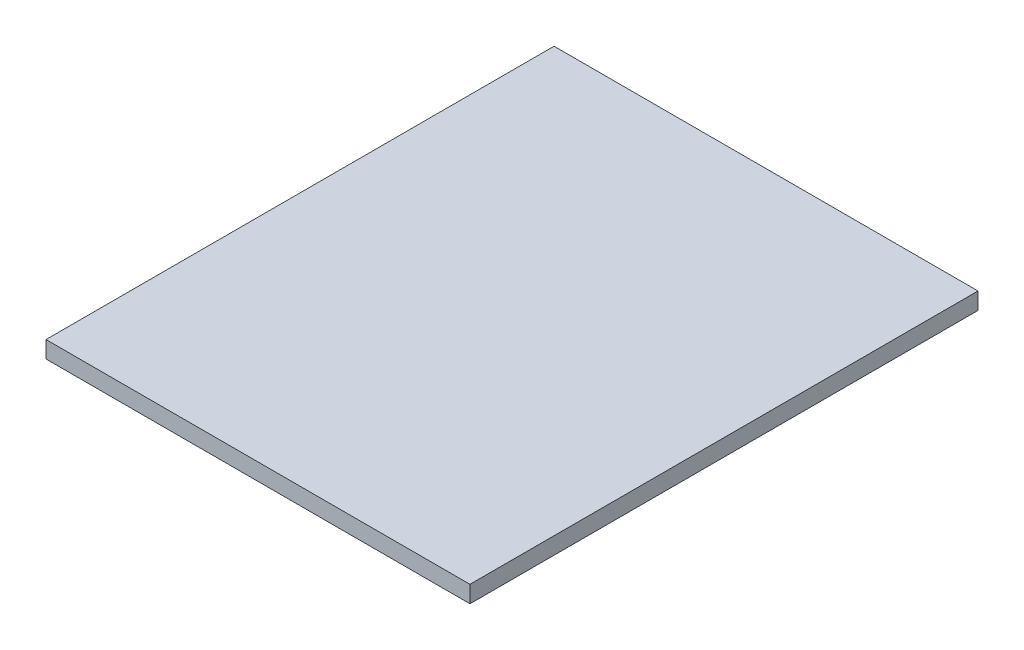
from build123d import *

# Parameters (mm, degrees)
SKETCH1_W           = 478.5
SKETCH1_H           = 573.438003792
BOSS_EXTRUDE1_DEPTH = 19.05


with BuildPart() as part:
    # Sketch1 → Boss-Extrude1 (new body)
    with BuildSketch(Plane(origin=(0, 0, 0), x_dir=(1, 0, 0), z_dir=(0, 1, 0))):
        with Locations((-106.745313805, 40.496846732)):
            Rectangle(SKETCH1_W, SKETCH1_H)
    extrude(amount=BOSS_EXTRUDE1_DEPTH)


solid = part.part
